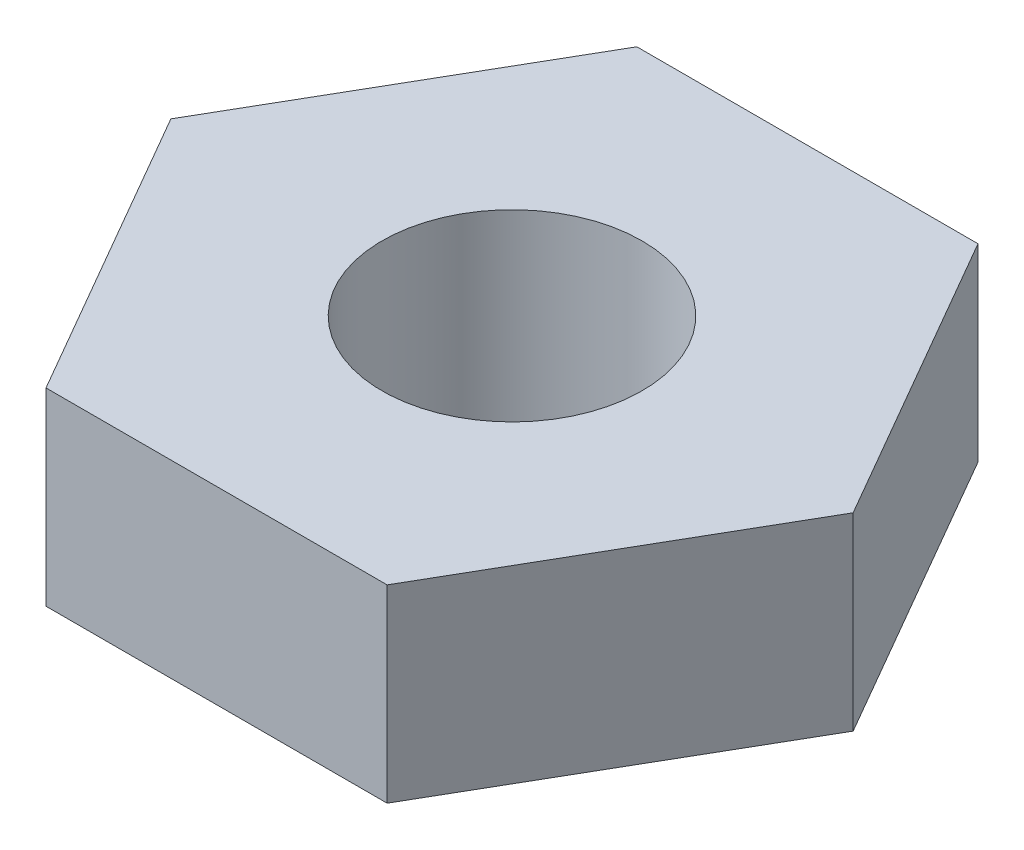
from build123d import *

# Parameters (mm, degrees)
BOSS_EXTRUDE1_DEPTH = 0.8
SKETCH2_R           = 0.55
CUT_EXTRUDE1_DEPTH  = 1.8


with BuildPart() as part:
    # Sketch1 → Boss-Extrude1 (new body)
    with BuildSketch(Plane(origin=(0, 0, 0), x_dir=(1, 0, 0), z_dir=(0, 1, 0))):
        Polygon((-0.721687934, 1.250000168), (-1.443375867, 0), (-0.721687934, -1.250000168), (0.721687934, -1.250000168), (1.443375867, 0), (0.721687934, 1.250000168), align=None)
    extrude(amount=BOSS_EXTRUDE1_DEPTH)

    # Sketch2 → Cut-Extrude1 (cut, through all)
    with BuildSketch(Plane.XZ):
        Circle(SKETCH2_R)
    extrude(amount=-CUT_EXTRUDE1_DEPTH, mode=Mode.SUBTRACT)


solid = part.part
